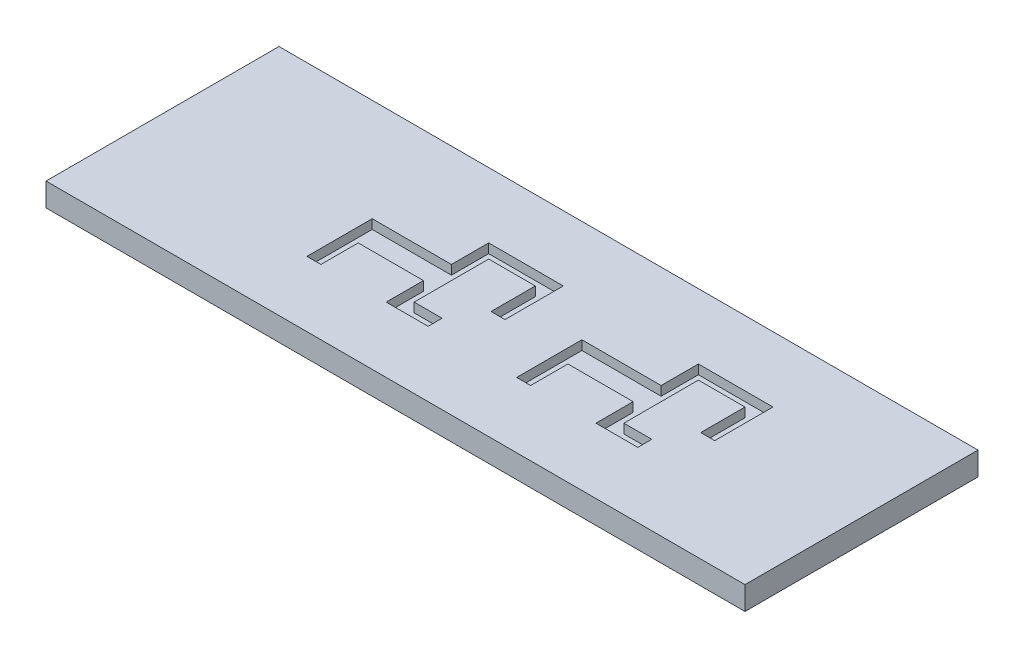
from build123d import *

# Parameters (mm, degrees)
SKETCH1_W           = 75
SKETCH1_H           = 25
BOSS_EXTRUDE1_DEPTH = 2.5
SKETCH2_W           = 1.5
SKETCH2_H           = 4
SKETCH2_H_2         = 2.5
SKETCH2_H_3         = 4.75
CUT_EXTRUDE1_DEPTH  = 1


with BuildPart() as part:
    # Sketch1 → Boss-Extrude1 (new body)
    with BuildSketch(Plane(origin=(0, 0, 0), x_dir=(1, 0, 0), z_dir=(0, 1, 0))):
        Rectangle(SKETCH1_W, SKETCH1_H)
    extrude(amount=BOSS_EXTRUDE1_DEPTH)

    # Sketch2 → Cut-Extrude1 (cut)
    with BuildSketch(Plane(origin=(0, 2.5, 0), x_dir=(1, 0, 0), z_dir=(0, 1, 0))):
        Polygon((6, 1.5), (6, -1.5), (7.5, -1.5), (14.5, -1.5), (16, -1.5), (16, -1), (16, 0), (16, 1.5), (14.5, 1.5), align=None)
        with Locations((6.75, -3.5)):
            Rectangle(SKETCH2_W, SKETCH2_H)
        with Locations((15.25, -2.75)):
            Rectangle(SKETCH2_W, SKETCH2_H_2)
        with Locations((15.25, 2.75)):
            Rectangle(SKETCH2_W, SKETCH2_H_2)
        Polygon((16, -4), (14.5, -4), (14.5, -5.5), (19, -5.5), (19, -4), align=None)
        Polygon((14.5, 5.5), (14.5, 4), (16, 4), (21, 4), (22.5, 4), (22.5, 5.5), align=None)
        with Locations((21.75, 1.625)):
            Rectangle(SKETCH2_W, SKETCH2_H_3)
        Polygon((-16.5, 1.5), (-16.5, -1.5), (-15, -1.5), (-8, -1.5), (-6.5, -1.5), (-6.5, -1), (-6.5, 0), (-6.5, 1.5), (-8, 1.5), align=None)
        with Locations((-15.75, -3.5)):
            Rectangle(SKETCH2_W, SKETCH2_H)
        with Locations((-7.25, -2.75)):
            Rectangle(SKETCH2_W, SKETCH2_H_2)
        with Locations((-7.25, 2.75)):
            Rectangle(SKETCH2_W, SKETCH2_H_2)
        Polygon((-6.5, -4), (-8, -4), (-8, -5.5), (-3.5, -5.5), (-3.5, -4), align=None)
        Polygon((-8, 5.5), (-8, 4), (-6.5, 4), (-1.5, 4), (0, 4), (0, 5.5), align=None)
        with Locations((-0.75, 1.625)):
            Rectangle(SKETCH2_W, SKETCH2_H_3)
    extrude(amount=-CUT_EXTRUDE1_DEPTH, mode=Mode.SUBTRACT)


solid = part.part
